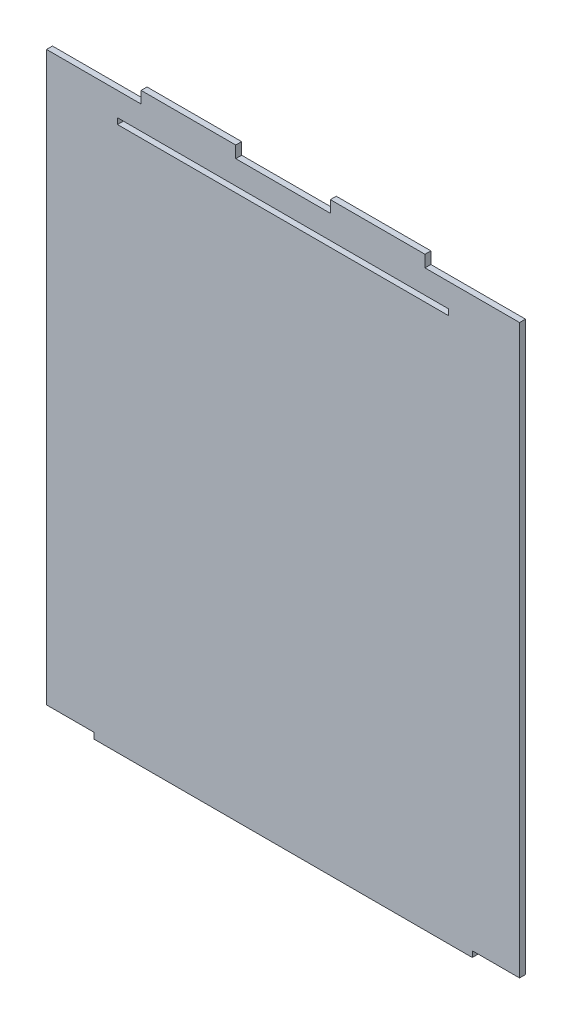
from build123d import *

# Parameters (mm, degrees)
SKETCH1_W           = 177.8
SKETCH1_H           = 3.175
BOSS_EXTRUDE1_DEPTH = 3.175


with BuildPart() as part:
    # Sketch1 → Boss-Extrude1 (new body)
    with BuildSketch(Plane.XY):
        Polygon((228.6, -6.35), (228.6, -3.175), (254, -3.175), (254, 301.625), (203.2, 301.625), (203.2, 307.975), (152.4, 307.975), (152.4, 301.625), (101.6, 301.625), (101.6, 307.975), (50.8, 307.975), (50.8, 301.625), (0, 301.625), (0, -3.175), (25.4, -3.175), (25.4, -6.35), align=None)
        with Locations((127, 287.3375)):
            Rectangle(SKETCH1_W, SKETCH1_H, mode=Mode.SUBTRACT)
    extrude(amount=BOSS_EXTRUDE1_DEPTH)


solid = part.part
